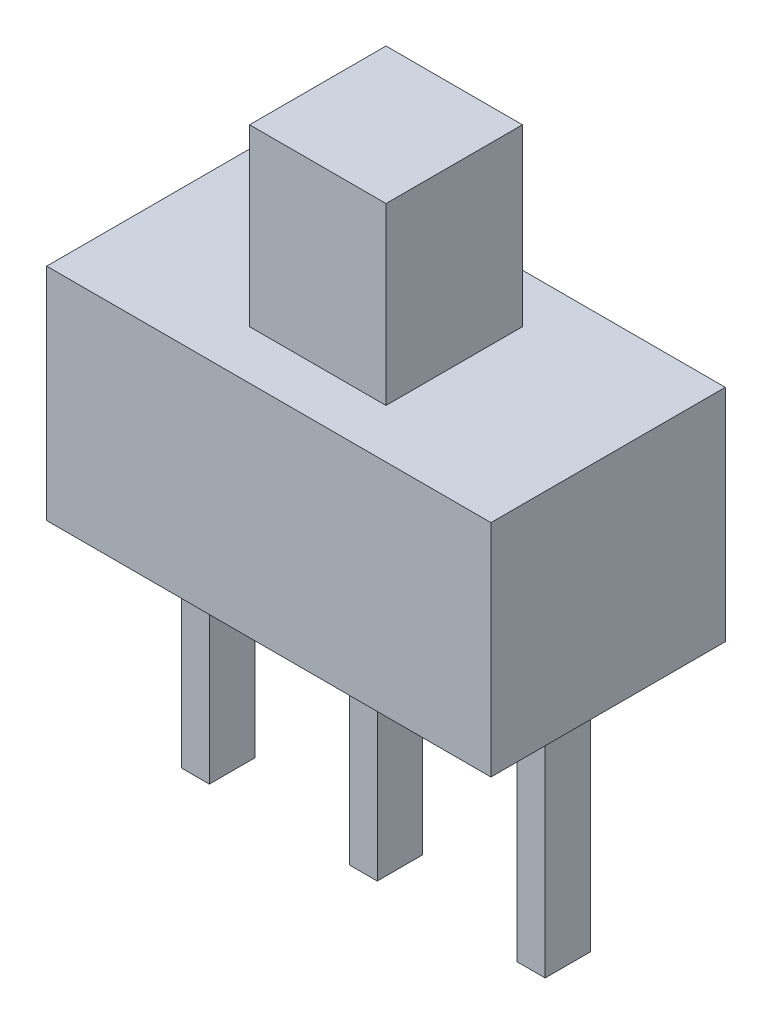
from build123d import *

# Parameters (mm, degrees)
SKETCH_1_W      = 12.7
SKETCH_1_H      = 6.7
EXTRUDE_1_DEPTH = 6.3
SKETCH_2_W      = 3.9
SKETCH_2_H      = 3.9
EXTRUDE_2_DEPTH = 5
SKETCH_3_W      = 0.8
SKETCH_3_H      = 1.3
EXTRUDE_3_DEPTH = 6.9


with BuildPart() as part:
    # 草图1 → 凸台-拉伸1 (new body)
    with BuildSketch(Plane(origin=(0, 0, 0), x_dir=(1, 0, 0), z_dir=(0, 1, 0))):
        Rectangle(SKETCH_1_W, SKETCH_1_H)
    extrude(amount=EXTRUDE_1_DEPTH)

    # 草图2 → 凸台-拉伸2 (add)
    with BuildSketch(Plane(origin=(0, 6.3, 0), x_dir=(1, 0, 0), z_dir=(0, 1, 0))):
        Rectangle(SKETCH_2_W, SKETCH_2_H)
    extrude(amount=EXTRUDE_2_DEPTH)

    # 草图3 → 凸台-拉伸3 (add)
    with BuildSketch(Plane.XZ):
        Rectangle(SKETCH_3_W, SKETCH_3_H)
        with Locations((4.8, 0)):
            Rectangle(SKETCH_3_W, SKETCH_3_H)
        with Locations((-4.8, 0)):
            Rectangle(SKETCH_3_W, SKETCH_3_H)
    extrude(amount=EXTRUDE_3_DEPTH)


solid = part.part
